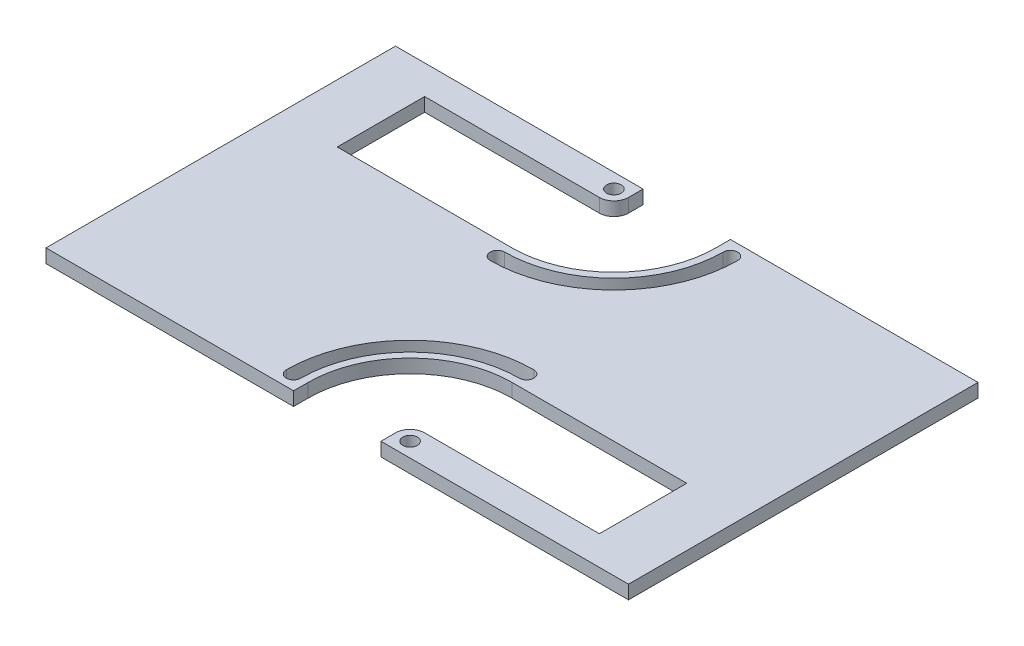
from build123d import *

# Parameters (mm, degrees)
SKETCH2_W           = 127
SKETCH2_H           = 76.2
BOSS_EXTRUDE1_DEPTH = 2.9718
SKETCH3_R           = 1.5875
CUT_EXTRUDE1_DEPTH  = 2.9718
CIRPATTERN1_COUNT   = 2


with BuildPart() as part:
    # Sketch2 → Boss-Extrude1 (new body)
    with BuildSketch(Plane(origin=(0, 0, 0), x_dir=(1, 0, 0), z_dir=(0, 1, 0))):
        Rectangle(SKETCH2_W, SKETCH2_H)
    extrude(amount=BOSS_EXTRUDE1_DEPTH)

    # Sketch3 → Cut-Extrude1 (cut)
    with BuildSketch(Plane(origin=(0, 2.9718, 0), x_dir=(1, 0, 0), z_dir=(0, 1, 0))):
        with BuildLine():
            ThreePointArc((12.7, -12.7), (-3.015448212, -19.209551788), (-9.525, -34.925))
            Line((-9.525, -34.925), (-9.525, -38.1))
            Line((-9.525, -38.1), (9.525, -38.1))
            Line((9.525, -38.1), (9.525, -34.925))
            ThreePointArc((9.525, -34.925), (10.45493597, -32.67993597), (12.7, -31.75))
            Line((12.7, -31.75), (50.8, -31.75))
            Line((50.8, -31.75), (50.8, -12.7))
            Line((50.8, -12.7), (12.7, -12.7))
        make_face()
        with Locations((12.7, -34.925)):
            Circle(SKETCH3_R)
        with BuildLine():
            ThreePointArc((12.7, -7.9375), (-6.383044257, -15.841955743), (-14.2875, -34.925))
            ThreePointArc((-14.2875, -34.925), (-12.7, -36.5125), (-11.1125, -34.925))
            ThreePointArc((-11.1125, -34.925), (-4.137980227, -18.087019773), (12.7, -11.1125))
            ThreePointArc((12.7, -11.1125), (14.2875, -9.525), (12.7, -7.9375))
        make_face()
    cut_extrude1 = extrude(amount=-CUT_EXTRUDE1_DEPTH, mode=Mode.SUBTRACT)

    # CirPattern1: Cut-Extrude1 ×2 about axis
    cirpattern1_axis = Axis((0, -0.14859, 0), (0, 1, 0))
    for i in range(1, CIRPATTERN1_COUNT):
        add(cut_extrude1.rotate(cirpattern1_axis, i * 360 / CIRPATTERN1_COUNT), mode=Mode.SUBTRACT)


solid = part.part
